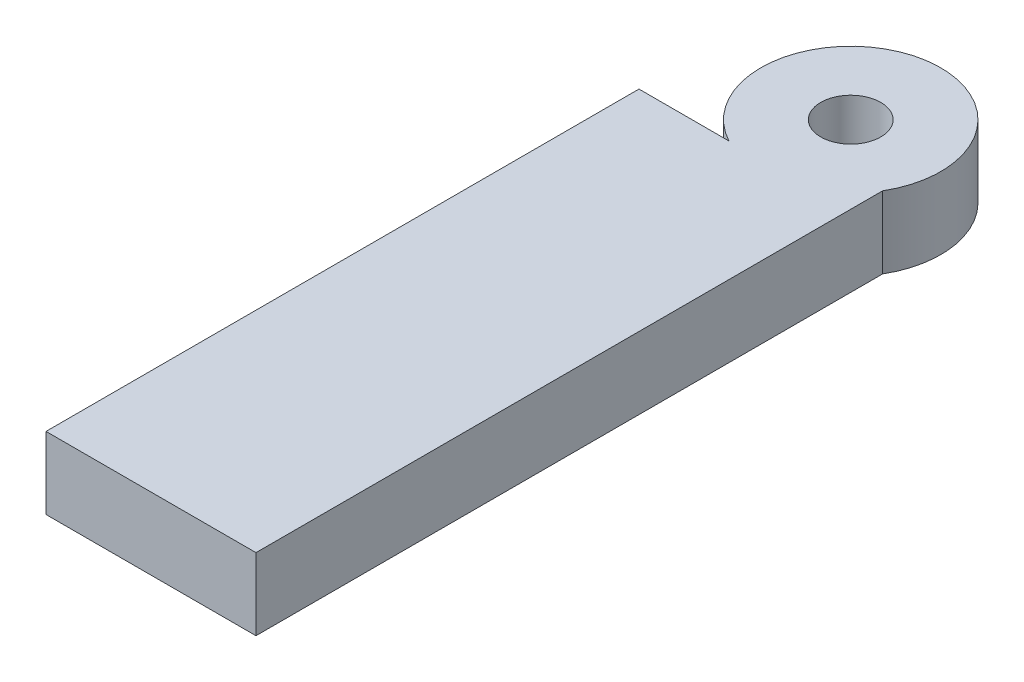
from build123d import *

# Parameters (mm, degrees)
SKETCH1_R           = 3.175
BOSS_EXTRUDE1_DEPTH = 7.62
SKETCH2_R           = 2.54
CUT_EXTRUDE1_DEPTH  = 6.35
SKETCH3_W           = 62.764867648
SKETCH3_H           = 7.62
SKETCH3_R           = 2.54
BOSS_EXTRUDE2_DEPTH = 9.525


with BuildPart() as part:
    # Sketch1 → Boss-Extrude1 (new body)
    with BuildSketch(Plane(origin=(0, 0, 0), x_dir=(1, 0, 0), z_dir=(0, 1, 0))):
        with BuildLine():
            Line((-4.490128061, -8.400260413), (-4.490128061, -71.165128061))
            Line((-4.490128061, -71.165128061), (8.209871939, -71.165128061))
            Line((8.209871939, -71.165128061), (8.209871939, -4.829454186))
            ThreePointArc((8.209871939, -4.829454186), (-2.578136518, 9.169451297), (-4.490128061, -8.400260413))
        make_face()
        Circle(SKETCH1_R, mode=Mode.SUBTRACT)
    extrude(amount=BOSS_EXTRUDE1_DEPTH)

    # Sketch2 → Cut-Extrude1 (cut)
    with BuildSketch(Plane.ZY.offset(4.490128061)):
        with Locations((14.750260413, 3.81)):
            Circle(SKETCH2_R)
        with Locations((52.850260413, 3.81)):
            Circle(SKETCH2_R)
    extrude(amount=-CUT_EXTRUDE1_DEPTH, mode=Mode.SUBTRACT)

    # Sketch3 → Boss-Extrude2 (add)
    with BuildSketch(Plane.ZY.offset(4.490128061)):
        with Locations((39.782694237, 3.81)):
            Rectangle(SKETCH3_W, SKETCH3_H)
        with Locations((52.850260413, 3.81)):
            Circle(SKETCH3_R, mode=Mode.SUBTRACT)
        with Locations((14.750260413, 3.81)):
            Circle(SKETCH3_R, mode=Mode.SUBTRACT)
    extrude(amount=BOSS_EXTRUDE2_DEPTH)


solid = part.part
